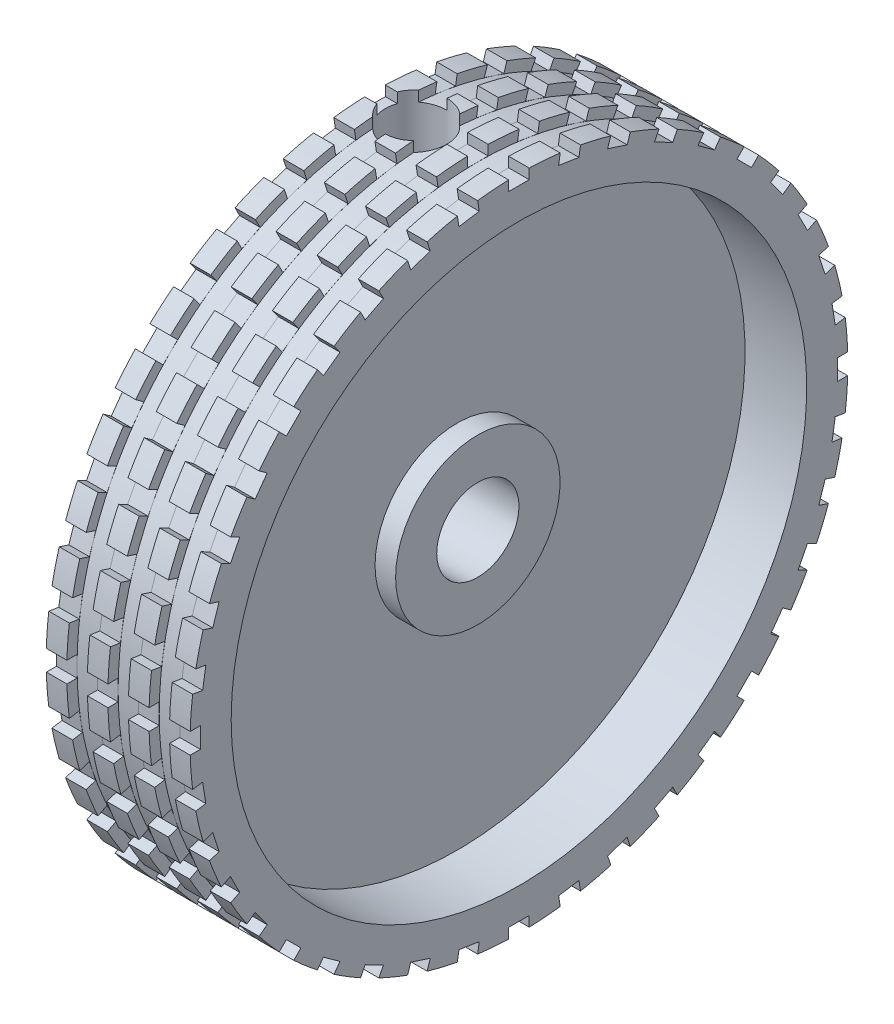
from build123d import *

# Parameters (mm, degrees)
SKETCH3_W          = 1
SKETCH3_H          = 0.5
SKETCH6_W          = 1
SKETCH6_H          = 1
CUT_EXTRUDE2_DEPTH = 10
CIRPATTERN1_COUNT  = 40
LPATTERN1_COUNT    = 3
LPATTERN1_PITCH    = 2


with BuildPart() as part:
    # Sketch1 → Revolve1 (revolve)
    with BuildSketch(Plane.XY):
        Polygon((0, 2), (0, 16), (7, 16), (7, 14), (4, 14), (4, 4), (5, 4), (5, 2), align=None)
    revolve(axis=Axis((0, 0, 0), (1, 0, 0)))

    # Sketch2 → Cut-Revolve2 (revolve, cut)
    with BuildSketch(Plane.XY):
        Polygon((2, 16), (3.5, 16), (3.5, 11.5), (2.9, 11.5), (2.9, 0), (2, 0), align=None)
    revolve(axis=Axis((2, 0, 0), (0, 1, 0)), mode=Mode.SUBTRACT)

    # Sketch3 → Cut-Revolve3 (revolve, cut)
    with BuildSketch(Plane.XY):
        with Locations((5.5, 15.75)):
            Rectangle(SKETCH3_W, SKETCH3_H)
    cut_revolve3 = revolve(axis=Axis((0, 0, 0), (1, 0, 0)), mode=Mode.SUBTRACT)

    # Sketch6 → Cut-Extrude2 (cut)
    with BuildSketch(Plane.ZY):
        with Locations((0, 16)):
            Rectangle(SKETCH6_W, SKETCH6_H)
    cut_extrude2 = extrude(amount=-CUT_EXTRUDE2_DEPTH, mode=Mode.SUBTRACT)

    # CirPattern1: Cut-Extrude2 ×40 about axis
    cirpattern1_axis = Axis((0, 0, 0), (1, 0, 0))
    for i in range(1, CIRPATTERN1_COUNT):
        add(cut_extrude2.rotate(cirpattern1_axis, i * 360 / CIRPATTERN1_COUNT), mode=Mode.SUBTRACT)

    # LPattern1: Cut-Revolve3 ×3
    with Locations(*[(-i * LPATTERN1_PITCH, 0, 0) for i in range(1, LPATTERN1_COUNT)]):
        add(cut_revolve3, mode=Mode.SUBTRACT)


solid = part.part
